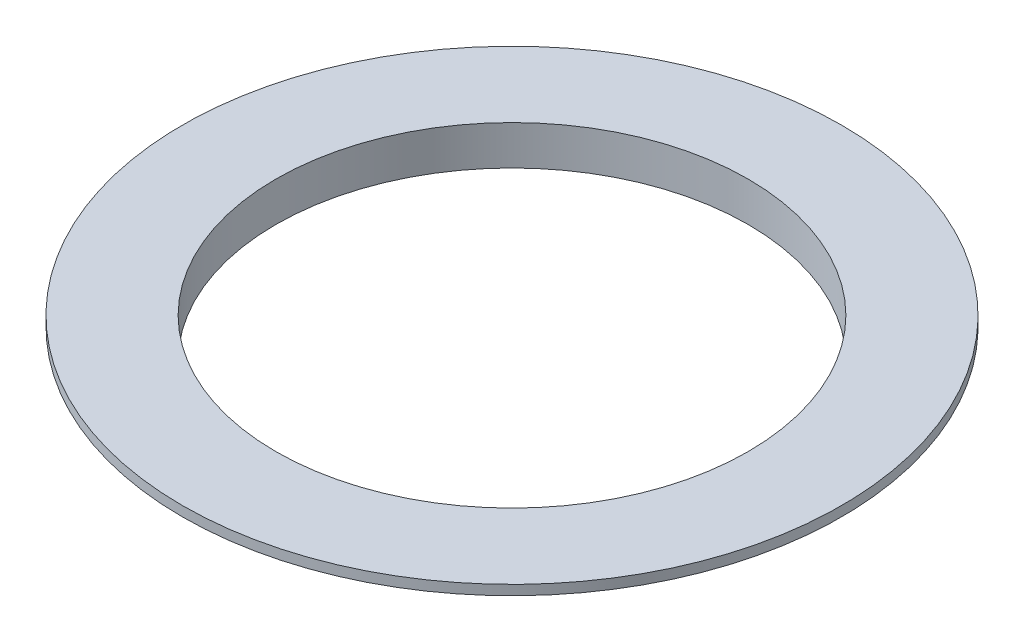
from build123d import *

# Parameters (mm, degrees)
SKETCH4_R          = 76.2
CUT_EXTRUDE1_DEPTH = 13.7


with BuildPart() as part:
    # Sketch1 → Revolve1 (revolve)
    with BuildSketch(Plane(origin=(0, 0, 0), x_dir=(0, 0, -1), z_dir=(1, 0, 0))):
        Polygon((50.8, 0), (80.9625, 0), (80.9625, 9.525), (106.3625, 9.525), (106.3625, 12.7), (0, 12.7), (0, 9.525), (50.8, 9.525), align=None)
    revolve(axis=Axis((0, 0, 0), (0, 1, 0)))

    # Sketch4 → Cut-Extrude1 (cut, through all)
    with BuildSketch(Plane(origin=(0, 12.7, 0), x_dir=(1, 0, 0), z_dir=(0, 1, 0))):
        Circle(SKETCH4_R)
    extrude(amount=-CUT_EXTRUDE1_DEPTH, mode=Mode.SUBTRACT)


solid = part.part
